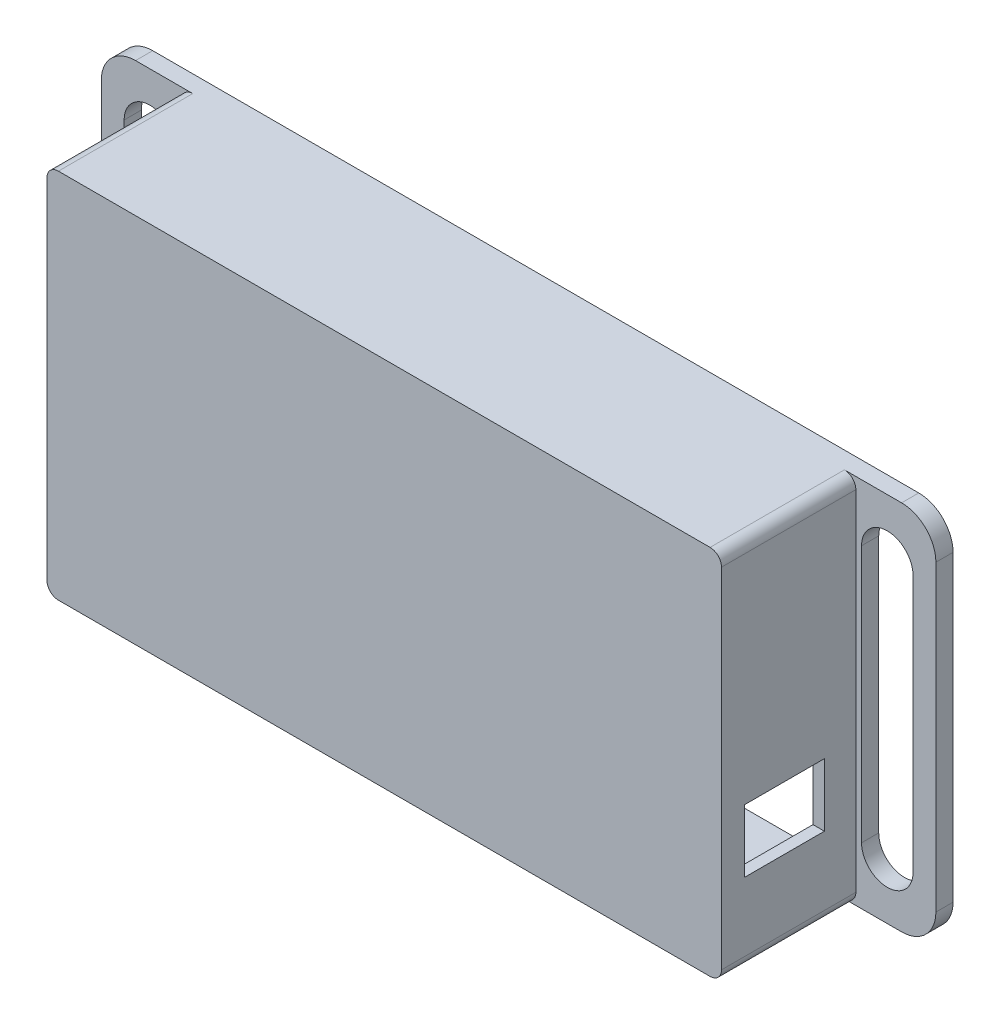
from build123d import *

# Parameters (mm, degrees)
SKETCH2_W            = 118
SKETCH2_H            = 65
BOSS_EXTRUDE2_DEPTH  = 1.5
SKETCH4_W            = 118
SKETCH4_H            = 65
SKETCH4_W_2          = 114
SKETCH4_H_2          = 61
BOSS_EXTRUDE3_DEPTH  = 25
SKETCH6_W            = 14
SKETCH6_H            = 65
BOSS_EXTRUDE4_DEPTH  = 3
FILLET1_R            = 6
FILLET1_OF_MIRROR1_R = 6
FILLET2_R            = 2
FILLET3_R            = 1
SKETCH7_W            = 14
SKETCH7_H            = 11
CUT_EXTRUDE1_DEPTH   = 10


with BuildPart() as part:
    # Sketch2 → Boss-Extrude2 (new body)
    with BuildSketch(Plane.XY):
        Rectangle(SKETCH2_W, SKETCH2_H)
    extrude(amount=BOSS_EXTRUDE2_DEPTH)

    # Sketch4 → Boss-Extrude3 (add)
    with BuildSketch(Plane.XY):
        Rectangle(SKETCH4_W, SKETCH4_H)
        Rectangle(SKETCH4_W_2, SKETCH4_H_2, mode=Mode.SUBTRACT)
    extrude(amount=-BOSS_EXTRUDE3_DEPTH)

    # Sketch6 → Boss-Extrude4 (add)
    with BuildSketch(Plane(origin=(0, 0, -25), x_dir=(-1, 0, 0), z_dir=(0, 0, -1))):
        with Locations((66, 0)):
            Rectangle(SKETCH6_W, SKETCH6_H)
        with BuildLine():
            Line((60, -22.5), (60, 22.5))
            ThreePointArc((60, 22.5), (64.5, 27), (69, 22.5))
            Line((69, 22.5), (69, -22.5))
            ThreePointArc((69, -22.5), (64.5, -27), (60, -22.5))
        make_face(mode=Mode.SUBTRACT)
    boss_extrude4 = extrude(amount=-BOSS_EXTRUDE4_DEPTH)

    # Fillet1
    fillet1_edges = [part.edges().sort_by_distance(p)[0] for p in [
        (-73, -32.5, -23.5),
        (-73, 32.5, -23.5),
    ]]
    fillet(fillet1_edges, radius=FILLET1_R)

    # Mirror1: Boss-Extrude4 across plane
    add(boss_extrude4.mirror(Plane(origin=(0, 0, 0), x_dir=(0, 0, 1), z_dir=(1, 0, 0))))

    # Fillet1 of Mirror1
    fillet1_of_mirror1_edges = [part.edges().sort_by_distance(p)[0] for p in [
        (73, -32.5, -23.5),
        (73, 32.5, -23.5),
    ]]
    fillet(fillet1_of_mirror1_edges, radius=FILLET1_OF_MIRROR1_R)

    # Fillet2
    fillet2_edges = [part.edges().sort_by_distance(p)[0] for p in [
        (-59, 32.5, -10.25),
        (-59, -32.5, -10.25),
        (59, 32.5, -10.25),
        (59, -32.5, -10.25),
    ]]
    fillet(fillet2_edges, radius=FILLET2_R)

    # Fillet3
    fillet3_edges = [part.edges().sort_by_distance(p)[0] for p in [
        (-57, -30.5, -12.5),
        (-57, 30.5, -12.5),
        (57, 30.5, -12.5),
        (57, -30.5, -12.5),
    ]]
    fillet(fillet3_edges, radius=FILLET3_R)

    # Sketch7 → Cut-Extrude1 (cut)
    with BuildSketch(Plane(origin=(59, 0, 0), x_dir=(0, 0, -1), z_dir=(1, 0, 0))):
        with Locations((9.5, -13)):
            Rectangle(SKETCH7_W, SKETCH7_H)
    extrude(amount=-CUT_EXTRUDE1_DEPTH, mode=Mode.SUBTRACT)


solid = part.part
